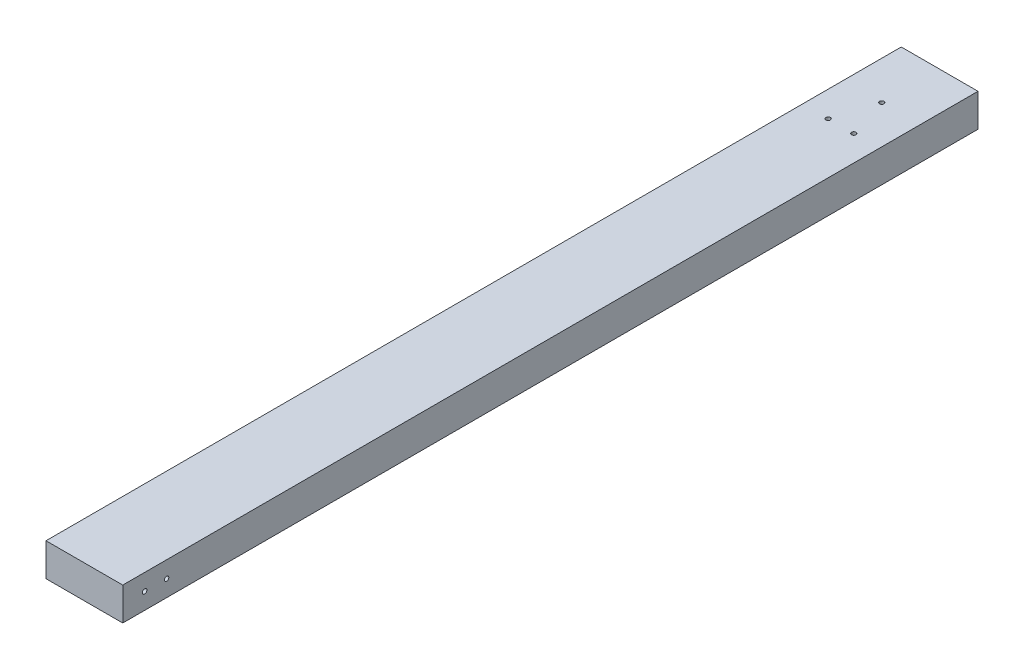
from build123d import *

# Parameters (mm, degrees)
SKETCH1_W           = 88.9
SKETCH1_H           = 38.1
BOSS_EXTRUDE1_DEPTH = 990.6
SKETCH2_R           = 2.5796875
CUT_EXTRUDE1_DEPTH  = 89.9
SKETCH3_R           = 2.5796875
CUT_EXTRUDE2_DEPTH  = 39.1


with BuildPart() as part:
    # Sketch1 → Boss-Extrude1 (new body)
    with BuildSketch(Plane.XY):
        with Locations((-44.45, 23.126988636)):
            Rectangle(SKETCH1_W, SKETCH1_H)
    extrude(amount=BOSS_EXTRUDE1_DEPTH)

    # Sketch2 → Cut-Extrude1 (cut, through all)
    with BuildSketch(Plane.ZY.offset(88.9)):
        with Locations((939.8, 23.126988636)):
            Circle(SKETCH2_R)
        with Locations((965.2, 23.126988636)):
            Circle(SKETCH2_R)
    extrude(amount=-CUT_EXTRUDE1_DEPTH, mode=Mode.SUBTRACT)

    # Sketch3 → Cut-Extrude2 (cut, through all)
    with BuildSketch(Plane.XZ.offset(-4.076988636)):
        with Locations((-44.45, 67.113890037)):
            Circle(SKETCH3_R)
        with Locations((-29.633333333, 114.3)):
            Circle(SKETCH3_R)
        with Locations((-59.266666667, 114.3)):
            Circle(SKETCH3_R)
    extrude(amount=-CUT_EXTRUDE2_DEPTH, mode=Mode.SUBTRACT)


solid = part.part
